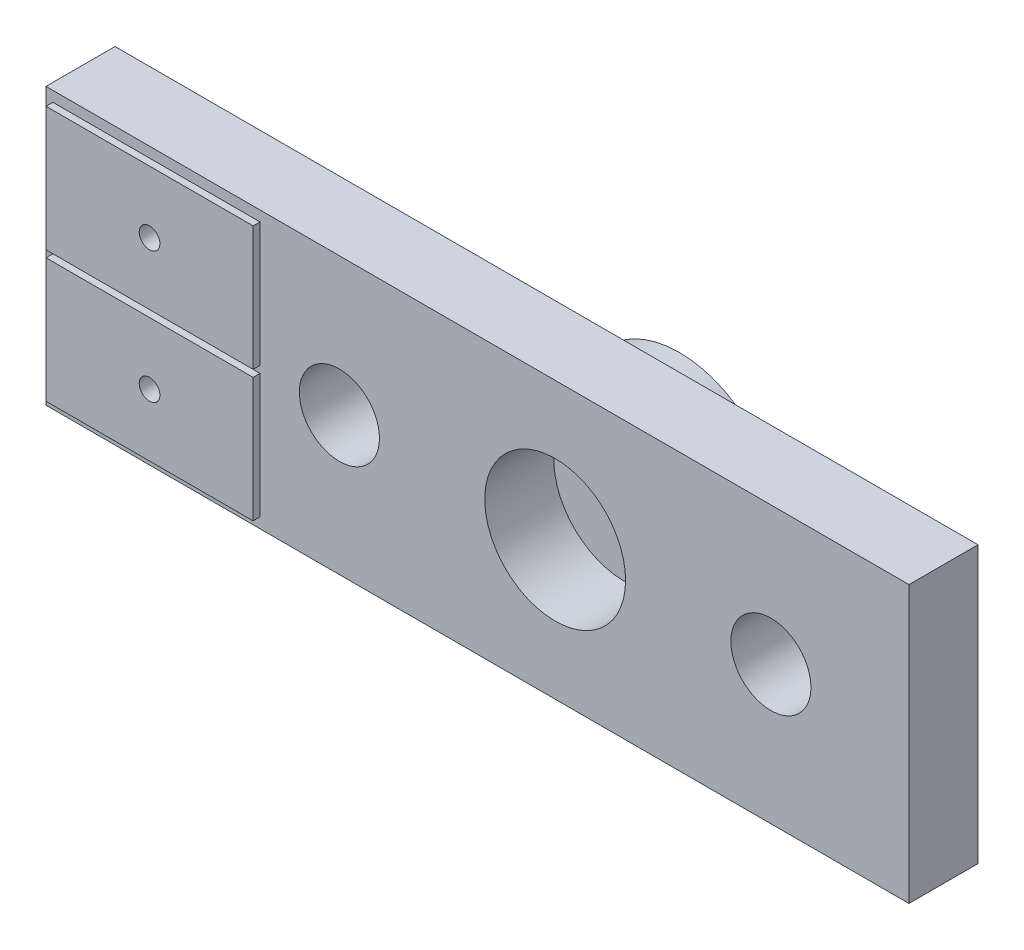
from build123d import *

# Parameters (mm, degrees)
SKETCH2_W                  = 31.75
SKETCH2_H                  = 10.16
SKETCH2_R                  = 1.4732
BOSS_EXTRUDE1_DEPTH        = 2.54
F_6_0_204_DIAMETER_HOLE1_D = 5.1816
SKETCH5_W                  = 7.62
SKETCH5_H                  = 4.572
BOSS_EXTRUDE2_DEPTH        = 0.254
SKETCH6_R                  = 0.381
CUT_EXTRUDE1_DEPTH         = 3.794
SKETCH7_R                  = 3.683
BOSS_EXTRUDE3_DEPTH        = 2.032


with BuildPart() as part:
    # Sketch2 → Boss-Extrude1 (new body)
    with BuildSketch(Plane.XY):
        with Locations((-0.381, 0)):
            Rectangle(SKETCH2_W, SKETCH2_H)
        with Locations((-5.461, 0)):
            Circle(SKETCH2_R, mode=Mode.SUBTRACT)
        with Locations((10.414, 0)):
            Circle(SKETCH2_R, mode=Mode.SUBTRACT)
    extrude(amount=BOSS_EXTRUDE1_DEPTH)

    # #6 (0.204) Diameter Hole1 (through all)
    with Locations(Plane(origin=(2.4765, 0, 2.54), x_dir=(1, 0, 0), z_dir=(0, 0, 1))):
        with Locations((0, 0)):
            Hole(F_6_0_204_DIAMETER_HOLE1_D / 2)

    # Sketch5 → Boss-Extrude2 (add)
    with BuildSketch(Plane.XY.offset(2.54)):
        with Locations((-12.192, 2.413)):
            Rectangle(SKETCH5_W, SKETCH5_H)
        with Locations((-12.192, -2.413)):
            Rectangle(SKETCH5_W, SKETCH5_H)
    extrude(amount=BOSS_EXTRUDE2_DEPTH)

    # Sketch6 → Cut-Extrude1 (cut, through all)
    with BuildSketch(Plane.XY.offset(2.794)):
        with Locations((-12.192, 2.413)):
            Circle(SKETCH6_R)
        with Locations((-12.192, -2.413)):
            Circle(SKETCH6_R)
    extrude(amount=-CUT_EXTRUDE1_DEPTH, mode=Mode.SUBTRACT)

    # Sketch7 → Boss-Extrude3 (add)
    with BuildSketch(Plane(origin=(0, 0, 0), x_dir=(-1, 0, 0), z_dir=(0, 0, -1))):
        with Locations((-2.4765, 0)):
            Circle(SKETCH7_R)
    extrude(amount=BOSS_EXTRUDE3_DEPTH)


solid = part.part
